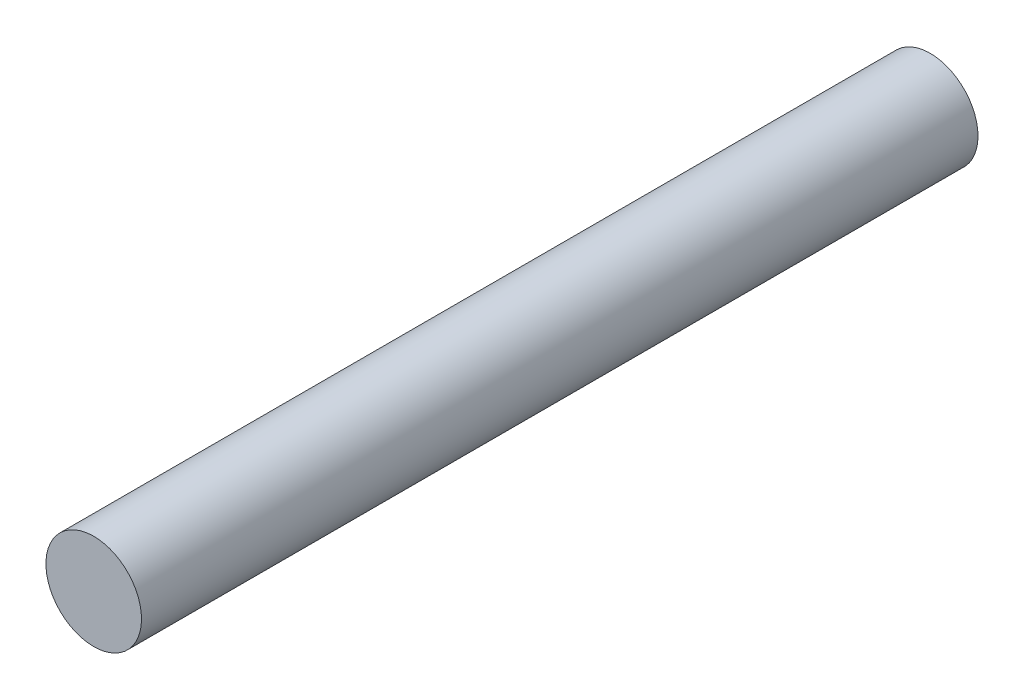
from build123d import *

# Parameters (mm, degrees)
SKETCH_1_R      = 4
EXTRUDE_1_DEPTH = 70


with BuildPart() as part:
    # 草图1 → 凸台-拉伸1 (new body)
    with BuildSketch(Plane.XY):
        Circle(SKETCH_1_R)
    extrude(amount=EXTRUDE_1_DEPTH)


solid = part.part
